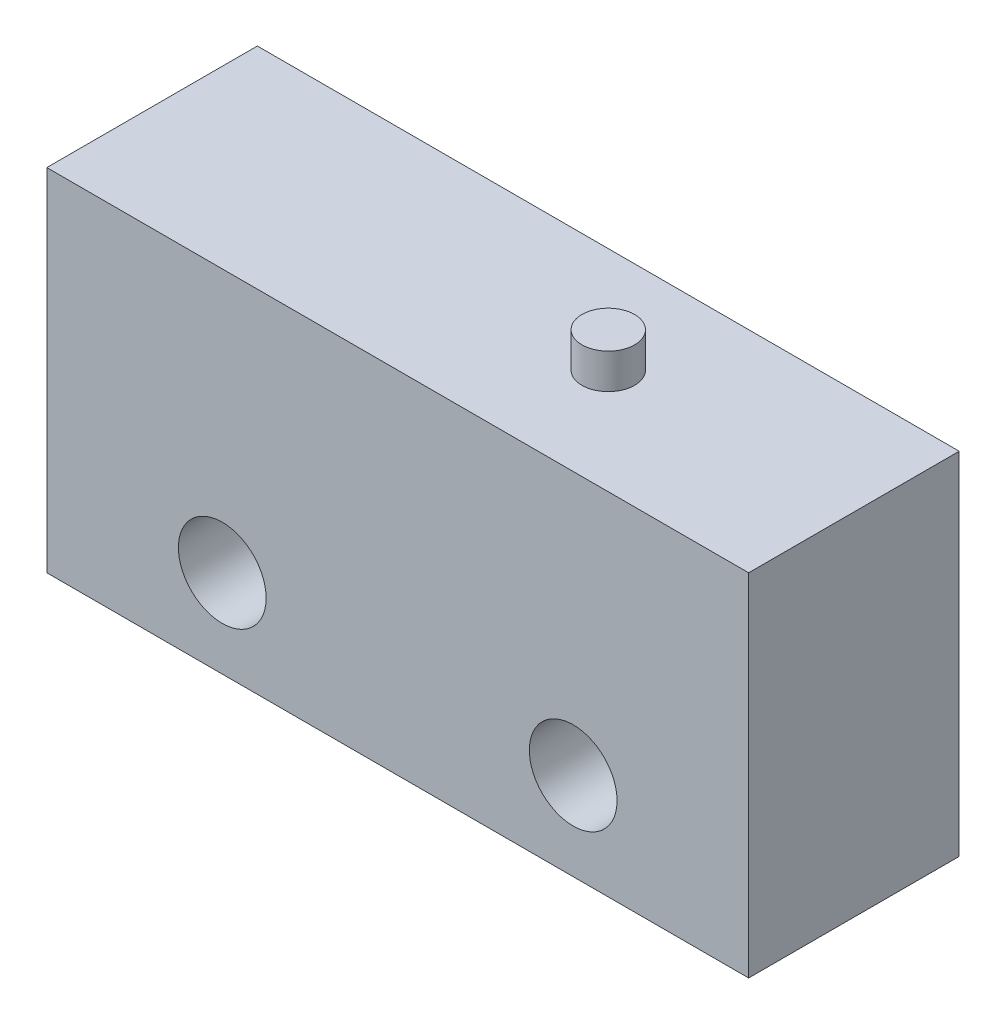
from build123d import *

# Parameters (mm, degrees)
SKETCH1_W           = 20
SKETCH1_H           = 10
SKETCH1_R           = 1.25
BOSS_EXTRUDE1_DEPTH = 6
SKETCH2_R           = 0.75
BOSS_EXTRUDE2_DEPTH = 1


with BuildPart() as part:
    # Sketch1 → Boss-Extrude1 (new body)
    with BuildSketch(Plane.XY):
        Rectangle(SKETCH1_W, SKETCH1_H)
        with Locations((-5, -2.5)):
            Circle(SKETCH1_R, mode=Mode.SUBTRACT)
        with Locations((5, -2.5)):
            Circle(SKETCH1_R, mode=Mode.SUBTRACT)
    extrude(amount=BOSS_EXTRUDE1_DEPTH)

    # Sketch2 → Boss-Extrude2 (add)
    with BuildSketch(Plane(origin=(0, 5, 0), x_dir=(1, 0, 0), z_dir=(0, 1, 0))):
        with Locations((3, -3)):
            Circle(SKETCH2_R)
    extrude(amount=BOSS_EXTRUDE2_DEPTH)


solid = part.part
